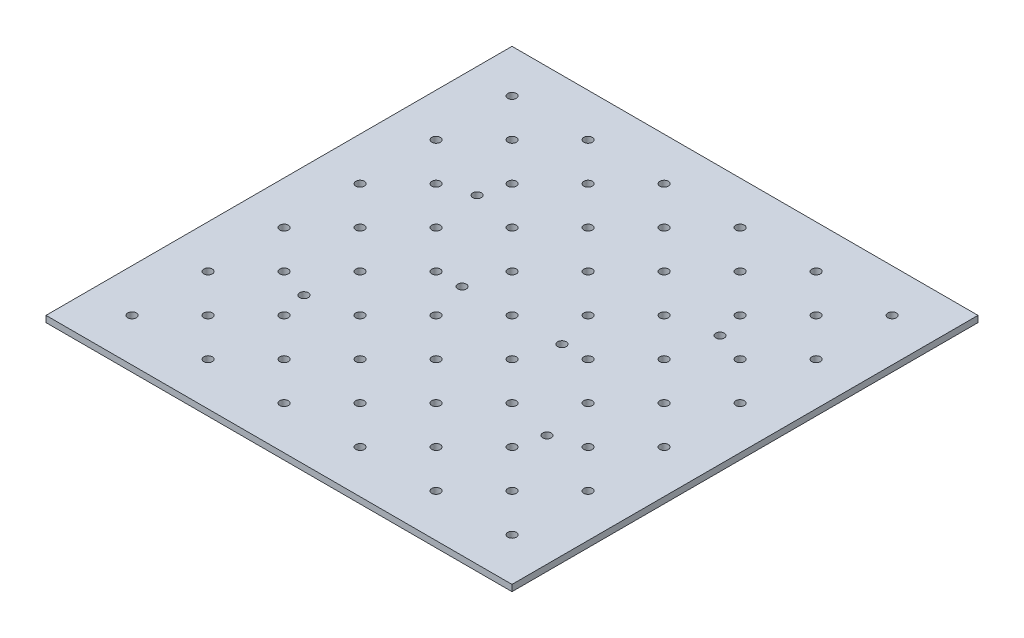
from build123d import *

# Parameters (mm, degrees)
SKETCH1_W           = 355.6
SKETCH1_H           = 355.6
BOSS_EXTRUDE1_DEPTH = 4.826
SKETCH3_R           = 3.2639
CUT_EXTRUDE2_DEPTH  = 5.826
SKETCH5_R           = 3.2639
CUT_EXTRUDE3_DEPTH  = 5.826
SKETCH6_R           = 3.2639
CUT_EXTRUDE4_DEPTH  = 5.826


with BuildPart() as part:
    # Sketch1 → Boss-Extrude1 (new body)
    with BuildSketch(Plane(origin=(0, 0, 0), x_dir=(1, 0, 0), z_dir=(0, 1, 0))):
        Rectangle(SKETCH1_W, SKETCH1_H)
    extrude(amount=BOSS_EXTRUDE1_DEPTH)

    # Sketch3 → Cut-Extrude2 (cut, through all)
    with BuildSketch(Plane.XZ):
        with Locations((92.71, -66.04)):
            Circle(SKETCH3_R)
        with Locations((92.71, 66.04)):
            Circle(SKETCH3_R)
        with Locations((38.1, 0)):
            Circle(SKETCH3_R)
        with Locations((-38.1, 0)):
            Circle(SKETCH3_R)
        with Locations((-92.71, 66.04)):
            Circle(SKETCH3_R)
        with Locations((-92.71, -66.04)):
            Circle(SKETCH3_R)
    extrude(amount=-CUT_EXTRUDE2_DEPTH, mode=Mode.SUBTRACT)

    # Sketch5 → Cut-Extrude3 (cut, through all)
    with BuildSketch(Plane.XZ):
        with Locations((145.034, -145.034)):
            Circle(SKETCH5_R)
        with Locations((87.034, -145.034)):
            Circle(SKETCH5_R)
        with Locations((29.034, -145.034)):
            Circle(SKETCH5_R)
        with Locations((-28.966, -145.034)):
            Circle(SKETCH5_R)
        with Locations((-86.966, -145.034)):
            Circle(SKETCH5_R)
        with Locations((-144.966, -145.034)):
            Circle(SKETCH5_R)
        with Locations((145.034, -87.034)):
            Circle(SKETCH5_R)
        with Locations((87.034, -87.034)):
            Circle(SKETCH5_R)
        with Locations((29.034, -87.034)):
            Circle(SKETCH5_R)
        with Locations((-28.966, -87.034)):
            Circle(SKETCH5_R)
        with Locations((-86.966, -87.034)):
            Circle(SKETCH5_R)
        with Locations((-144.966, -87.034)):
            Circle(SKETCH5_R)
        with Locations((145.034, -29.034)):
            Circle(SKETCH5_R)
        with Locations((87.034, -29.034)):
            Circle(SKETCH5_R)
        with Locations((29.034, -29.034)):
            Circle(SKETCH5_R)
        with Locations((-28.966, -29.034)):
            Circle(SKETCH5_R)
        with Locations((-86.966, -29.034)):
            Circle(SKETCH5_R)
        with Locations((-144.966, -29.034)):
            Circle(SKETCH5_R)
        with Locations((145.034, 28.966)):
            Circle(SKETCH5_R)
        with Locations((87.034, 28.966)):
            Circle(SKETCH5_R)
        with Locations((29.034, 28.966)):
            Circle(SKETCH5_R)
        with Locations((-28.966, 28.966)):
            Circle(SKETCH5_R)
        with Locations((-86.966, 28.966)):
            Circle(SKETCH5_R)
        with Locations((-144.966, 28.966)):
            Circle(SKETCH5_R)
        with Locations((145.034, 86.966)):
            Circle(SKETCH5_R)
        with Locations((87.034, 86.966)):
            Circle(SKETCH5_R)
        with Locations((29.034, 86.966)):
            Circle(SKETCH5_R)
        with Locations((-28.966, 86.966)):
            Circle(SKETCH5_R)
        with Locations((-86.966, 86.966)):
            Circle(SKETCH5_R)
        with Locations((-144.966, 86.966)):
            Circle(SKETCH5_R)
        with Locations((145.034, 144.966)):
            Circle(SKETCH5_R)
        with Locations((87.034, 144.966)):
            Circle(SKETCH5_R)
        with Locations((29.034, 144.966)):
            Circle(SKETCH5_R)
        with Locations((-28.966, 144.966)):
            Circle(SKETCH5_R)
        with Locations((-86.966, 144.966)):
            Circle(SKETCH5_R)
        with Locations((-144.966, 144.966)):
            Circle(SKETCH5_R)
    extrude(amount=-CUT_EXTRUDE3_DEPTH, mode=Mode.SUBTRACT)

    # Sketch6 → Cut-Extrude4 (cut, through all)
    with BuildSketch(Plane.XZ):
        with Locations((116.034, -116.034)):
            Circle(SKETCH6_R)
        with Locations((58.034, -116.034)):
            Circle(SKETCH6_R)
        with Locations((0.034, -116.034)):
            Circle(SKETCH6_R)
        with Locations((-57.966, -116.034)):
            Circle(SKETCH6_R)
        with Locations((-115.966, -116.034)):
            Circle(SKETCH6_R)
        with Locations((116.034, -58.034)):
            Circle(SKETCH6_R)
        with Locations((58.034, -58.034)):
            Circle(SKETCH6_R)
        with Locations((0.034, -58.034)):
            Circle(SKETCH6_R)
        with Locations((-57.966, -58.034)):
            Circle(SKETCH6_R)
        with Locations((-115.966, -58.034)):
            Circle(SKETCH6_R)
        with Locations((116.034, -0.034)):
            Circle(SKETCH6_R)
        with Locations((58.034, -0.034)):
            Circle(SKETCH6_R)
        with Locations((0.034, -0.034)):
            Circle(SKETCH6_R)
        with Locations((-57.966, -0.034)):
            Circle(SKETCH6_R)
        with Locations((-115.966, -0.034)):
            Circle(SKETCH6_R)
        with Locations((116.034, 57.966)):
            Circle(SKETCH6_R)
        with Locations((58.034, 57.966)):
            Circle(SKETCH6_R)
        with Locations((0.034, 57.966)):
            Circle(SKETCH6_R)
        with Locations((-57.966, 57.966)):
            Circle(SKETCH6_R)
        with Locations((-115.966, 57.966)):
            Circle(SKETCH6_R)
        with Locations((116.034, 115.966)):
            Circle(SKETCH6_R)
        with Locations((58.034, 115.966)):
            Circle(SKETCH6_R)
        with Locations((0.034, 115.966)):
            Circle(SKETCH6_R)
        with Locations((-57.966, 115.966)):
            Circle(SKETCH6_R)
        with Locations((-115.966, 115.966)):
            Circle(SKETCH6_R)
    extrude(amount=-CUT_EXTRUDE4_DEPTH, mode=Mode.SUBTRACT)


solid = part.part
